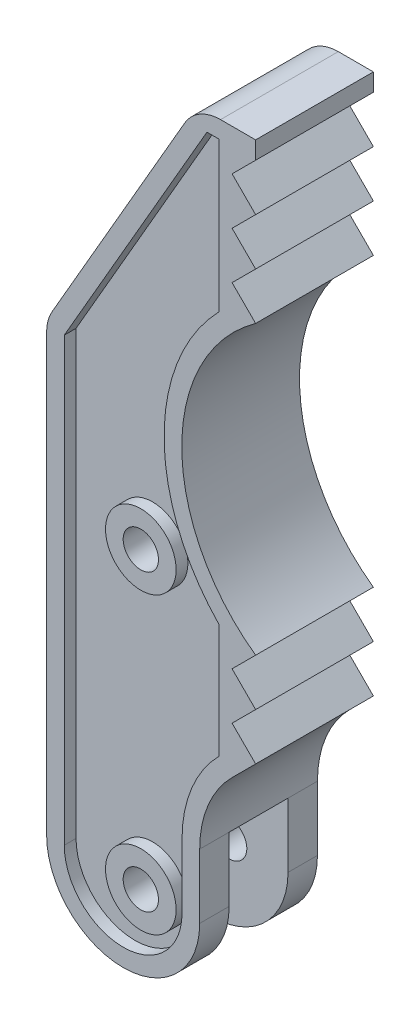
from build123d import *

# Parameters (mm, degrees)
SKETCH1_R           = 1.5
BOSS_EXTRUDE1_DEPTH = 5
CUT_EXTRUDE1_DEPTH  = 2.5
CUT_EXTRUDE2_DEPTH  = 1
SKETCH5_R           = 3
SKETCH5_R_2         = 1.5
EXTRUDE_THIN1_DEPTH = 1
FILLET1_R           = 3.5


with BuildPart() as part:
    # Sketch1 → Boss-Extrude1 (new body, symmetric)
    with BuildSketch(Plane.XY):
        with BuildLine():
            Line((0, 58.5), (-2, 56.5))
            Line((-2, 56.5), (0, 54.5))
            Line((0, 54.5), (-2, 52.5))
            Line((-2, 52.5), (0, 50.5))
            Line((0, 50.5), (-2, 48.5))
            Line((-2, 48.5), (0, 46.5))
            ThreePointArc((0, 46.5), (-6.273030308, 34.3), (0, 22.1))
            Line((0, 22.1), (-2, 20.1))
            Line((-2, 20.1), (0, 18.1))
            Line((0, 18.1), (-2, 16.1))
            Line((-2, 16.1), (0, 14.1))
            Line((0, 14.1), (-2, 12.1))
            ThreePointArc((-2, 12.1), (-4.035298286, 9.053960857), (-4.75, 5.460912703))
            Line((-4.75, 5.460912703), (-4.75, 0))
            ThreePointArc((-4.75, 0), (-11.25, -6.5), (-17.75, 0))
            Line((-17.75, 0), (-17.75, 37.916352203))
            Line((-17.75, 37.916352203), (-5, 60))
            Line((-5, 60), (0, 60))
            Line((0, 60), (0, 58.5))
        make_face()
        with Locations((-9.75, 0)):
            Circle(SKETCH1_R, mode=Mode.SUBTRACT)
        with Locations((-9.75, 25)):
            Circle(SKETCH1_R, mode=Mode.SUBTRACT)
    extrude(amount=BOSS_EXTRUDE1_DEPTH, both=True)

    # Sketch3 → Cut-Extrude1 (cut, symmetric)
    with BuildSketch(Plane.XY):
        with BuildLine():
            Line((-15, -38.410797367), (-15, -6.410797367))
            ThreePointArc((-15, -6.410797367), (-12.082951062, 1.431396204), (-4.75, 5.460912703))
            Line((-4.75, 5.460912703), (-4.75, -38.410797367))
            Line((-4.75, -38.410797367), (-15, -38.410797367))
        make_face()
    extrude(amount=CUT_EXTRUDE1_DEPTH, both=True, mode=Mode.SUBTRACT)

    # Sketch4 → Cut-Extrude2 (cut)
    with BuildSketch(Plane.XY.offset(5)):
        with BuildLine():
            Line((-3.12764747, 58.5), (-4.133974596, 58.5))
            Line((-4.133974596, 58.5), (-16.25, 37.514428415))
            Line((-16.25, 37.514428415), (-16.25, 0))
            ThreePointArc((-16.25, 0), (-11.25, -5), (-6.25, 0))
            Line((-6.25, 0), (-6.25, 5.460912703))
            ThreePointArc((-6.25, 5.460912703), (-5.439227916, 9.583992212), (-3.12764747, 13.093084951))
            Line((-3.12764747, 13.093084951), (-3.12764747, 22.82315148))
            ThreePointArc((-3.12764747, 22.82315148), (-7.773030308, 34.3), (-3.12764747, 45.77684852))
            Line((-3.12764747, 45.77684852), (-3.12764747, 58.5))
        make_face()
    extrude(amount=-CUT_EXTRUDE2_DEPTH, mode=Mode.SUBTRACT)

    # Sketch5 → Extrude-Thin1 (add)
    with BuildSketch(Plane.XY.offset(4)):
        with Locations((-9.75, 0)):
            Circle(SKETCH5_R)
        with Locations((-9.75, 0)):
            Circle(SKETCH5_R_2, mode=Mode.SUBTRACT)
        with Locations((-9.75, 25)):
            Circle(SKETCH5_R)
        with Locations((-9.75, 25)):
            Circle(SKETCH5_R_2, mode=Mode.SUBTRACT)
    extrude(amount=EXTRUDE_THIN1_DEPTH)

    # Fillet1
    fillet1_edges = [part.edges().sort_by_distance(p)[0] for p in [
        (-17.75, 37.916352203, 0),
        (-5, 60, 0),
    ]]
    fillet(fillet1_edges, radius=FILLET1_R)


solid = part.part
